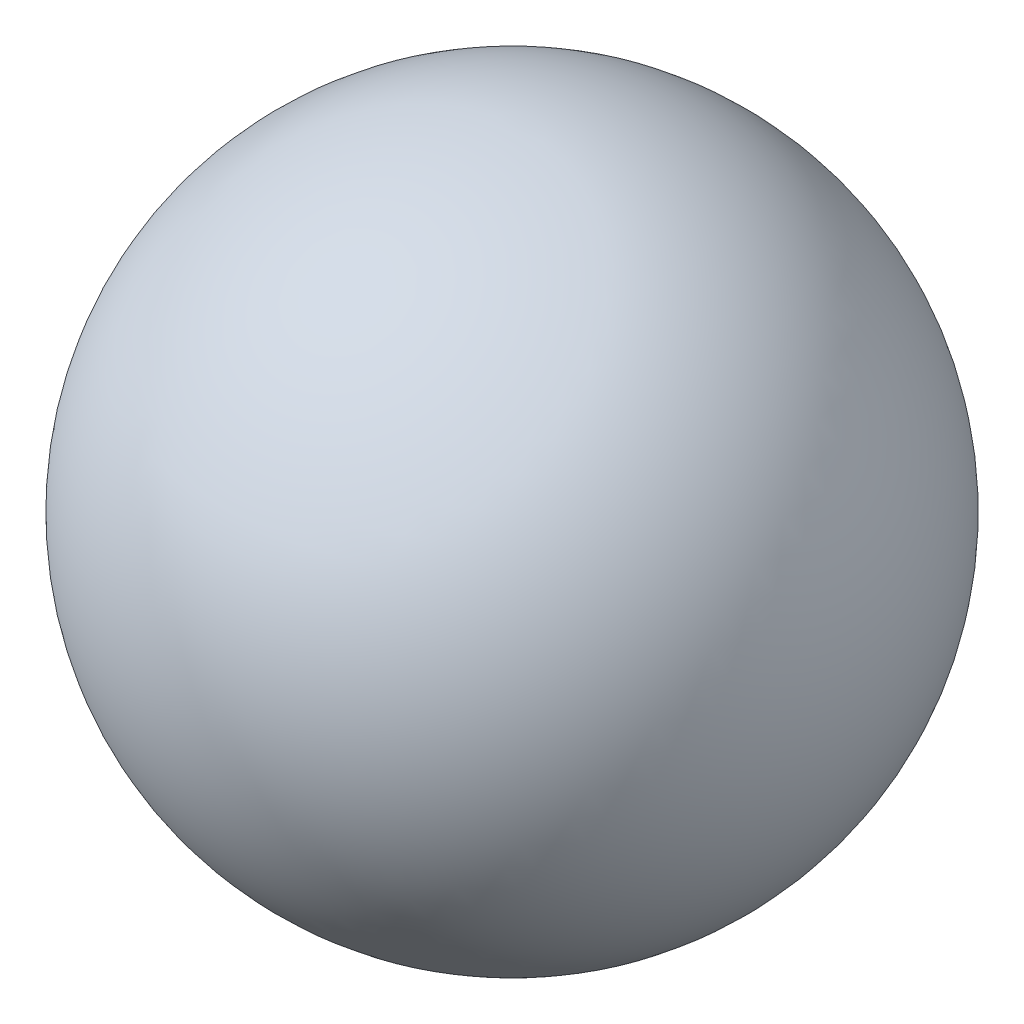
from build123d import *


with BuildPart() as part:
    # 草图1 → 旋转1 (revolve)
    with BuildSketch(Plane.XY):
        with BuildLine():
            Line((0, 1.8), (0, -1.8))
            ThreePointArc((0, -1.8), (-1.8, 0), (0, 1.8))
        make_face()
    revolve(axis=Axis((0, 1.8, 0), (0, -1, 0)))


solid = part.part
